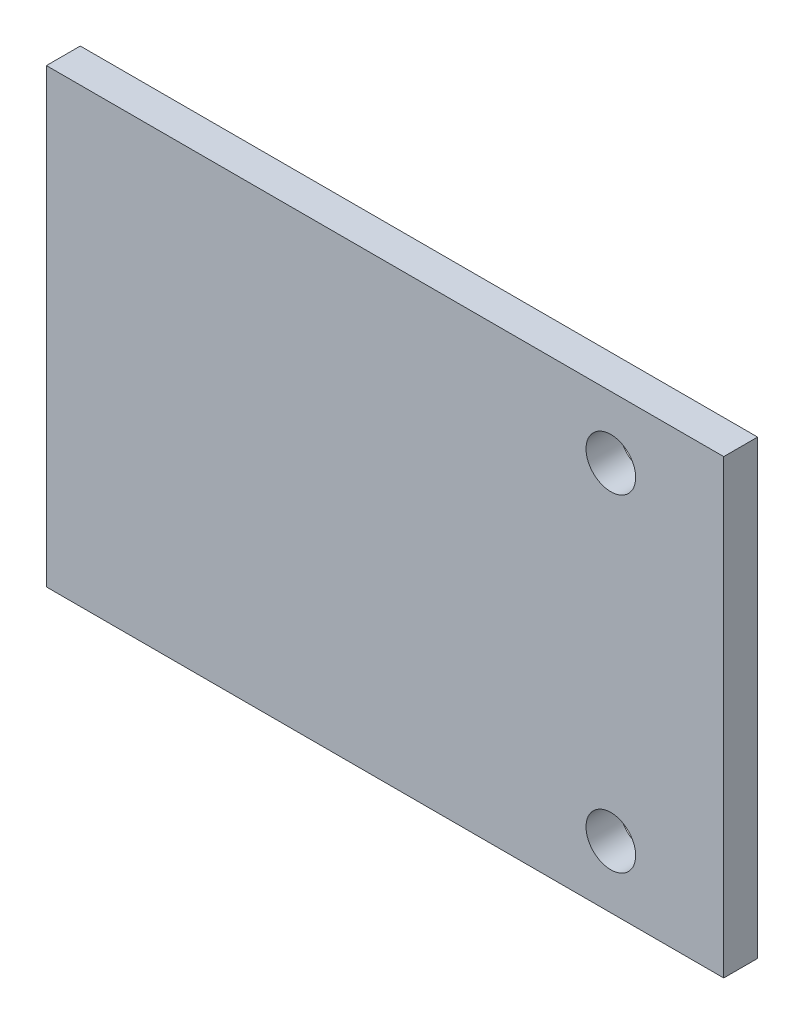
from build123d import *

# Parameters (mm, degrees)
SKETCH_1_W          = 60
SKETCH_1_H          = 40
EXTRUDE_1_DEPTH     = 3
CUT_EXTRUDE_1_DEPTH = 3


with BuildPart() as part:
    # ｽｹｯﾁ1 → ﾎﾞｽ - 押し出し1 (new body)
    with BuildSketch(Plane.XY):
        Rectangle(SKETCH_1_W, SKETCH_1_H)
    extrude(amount=EXTRUDE_1_DEPTH)

    # ｽｹｯﾁ2 → ｶｯﾄ - 押し出し1 (cut)
    with BuildSketch(Plane.XY.offset(3)):
        with BuildLine():
            ThreePointArc((22.2, 14.5), (21.555634919, 16.055634919), (20, 16.7))
            Line((20, 16.7), (20, 14.5))
            Line((20, 14.5), (22.2, 14.5))
        make_face()
        with BuildLine():
            Line((20, 14.5), (20, 16.7))
            ThreePointArc((20, 16.7), (18.444365081, 12.944365081), (22.2, 14.5))
            Line((22.2, 14.5), (20, 14.5))
        make_face()
        with BuildLine():
            ThreePointArc((22.2, -14.5), (18.444365081, -12.944365081), (20, -16.7))
            Line((20, -16.7), (20, -14.5))
            Line((20, -14.5), (22.2, -14.5))
        make_face()
        with BuildLine():
            Line((20, -14.5), (20, -16.7))
            ThreePointArc((20, -16.7), (21.555634919, -16.055634919), (22.2, -14.5))
            Line((22.2, -14.5), (20, -14.5))
        make_face()
    extrude(amount=-CUT_EXTRUDE_1_DEPTH, mode=Mode.SUBTRACT)


solid = part.part
